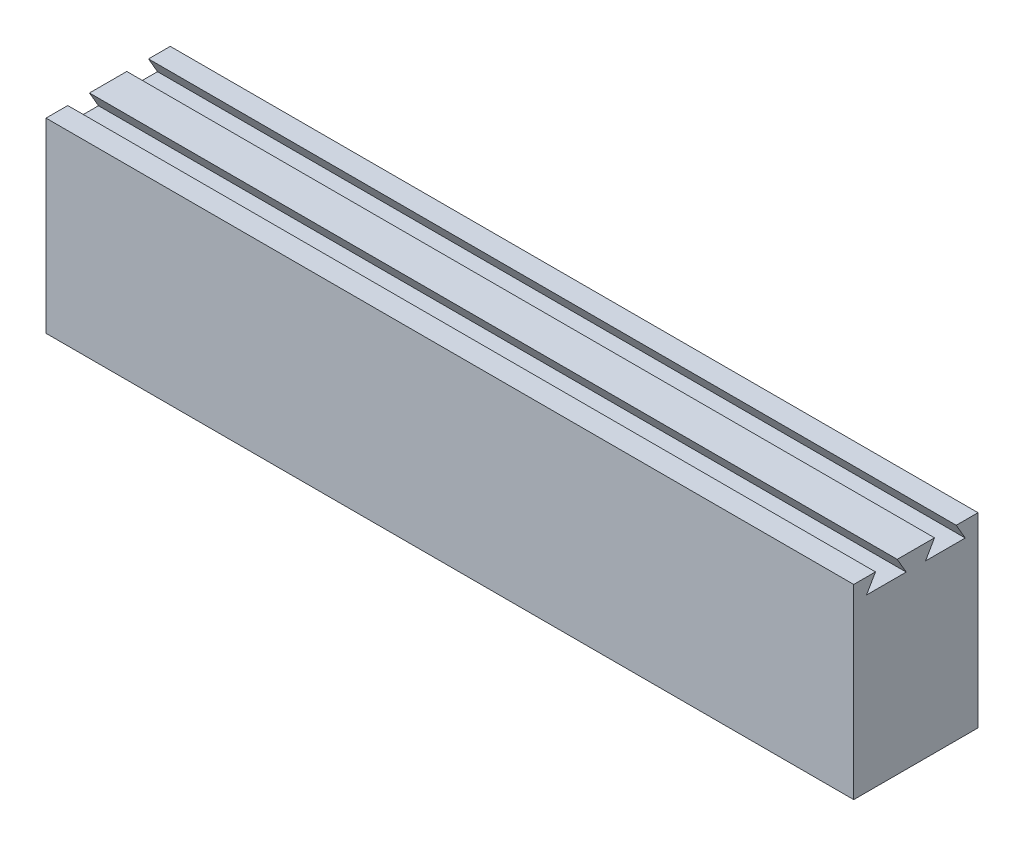
from build123d import *

# Parameters (mm, degrees)
BOSS_EXTRUDE1_DEPTH = 65


with BuildPart() as part:
    # Sketch1 → Boss-Extrude1 (new body, symmetric)
    with BuildSketch(Plane(origin=(0, 0, 0), x_dir=(0, 0, -1), z_dir=(1, 0, 0))):
        Polygon((1.555, 12.497186583), (3, 15), (0, 15), (-3, 15), (-1.555, 12.497186583), (-7.945, 12.497186583), (-6.5, 15), (-10, 15), (-10, -15), (10, -15), (10, 15), (6.5, 15), (7.945, 12.497186583), align=None)
    extrude(amount=BOSS_EXTRUDE1_DEPTH, both=True)


solid = part.part
